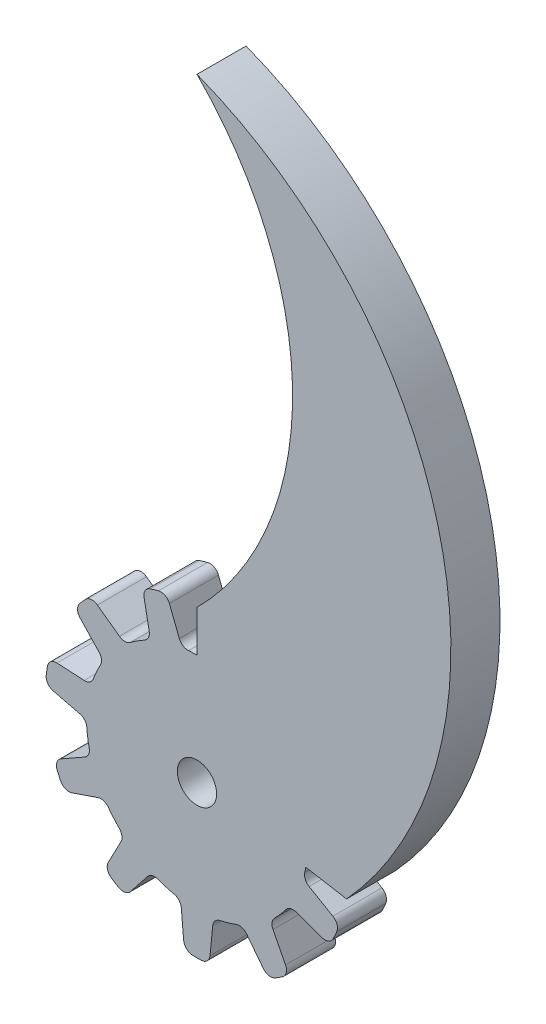
from build123d import *

# Parameters (mm, degrees)
ESBO_O1_R                = 1.6
RESSALTO_EXTRUS_O1_DEPTH = 4
RESSALTO_EXTRUS_O2_START = -4
RESSALTO_EXTRUS_O2_DEPTH = 4


with BuildPart() as part:
    # Esboço1 → Ressalto-extrusão1 (new body)
    with BuildSketch(Plane.XY):
        with BuildLine():
            Line((-5.428931338, -10.411256864), (-4.040153116, -8.653603149))
            ThreePointArc((-4.040153116, -8.653603149), (-3.651813796, -8.395770502), (-3.186165661, -8.417146095))
            ThreePointArc((-3.186165661, -8.417146095), (-2.535977815, -8.635323765), (-1.871064211, -8.803358377))
            ThreePointArc((-1.871064211, -8.803358377), (-1.465141223, -9.040151498), (-1.27980553, -9.472002324))
            Line((-1.27980553, -9.472002324), (-1.087391415, -11.684866251))
            ThreePointArc((-1.087391415, -11.684866251), (-0.855086446, -12.165243662), (-0.362160028, -12.369575749))
            ThreePointArc((-0.362160028, -12.369575749), (-0.013315066, -12.374869163), (0.335540479, -12.370326458))
            ThreePointArc((0.335540479, -12.370326458), (0.826548297, -12.16926195), (1.061642754, -11.693608494))
            Line((1.061642754, -11.693608494), (1.279697998, -9.464145904))
            ThreePointArc((1.279697998, -9.464145904), (1.466994971, -9.037291191), (1.870279627, -8.803525096))
            ThreePointArc((1.870279627, -8.803525096), (2.535208203, -8.635549743), (3.185415492, -8.41743002))
            ThreePointArc((3.185415492, -8.41743002), (3.654919666, -8.397174533), (4.044310156, -8.660270526))
            Line((4.044310156, -8.660270526), (5.402543773, -10.417823198))
            ThreePointArc((5.402543773, -10.417823198), (5.857682784, -10.696348844), (6.382829142, -10.601747792))
            ThreePointArc((6.382829142, -10.601747792), (6.679158034, -10.41760107), (6.970178022, -10.225173956))
            ThreePointArc((6.970178022, -10.225173956), (7.274536404, -9.790568861), (7.215152773, -9.263322051))
            Line((7.215152773, -9.263322051), (6.19325404, -7.269889205))
            ThreePointArc((6.19325404, -7.269889205), (6.120043199, -6.809535782), (6.332924348, -6.394847082))
            ThreePointArc((6.332924348, -6.394847082), (6.80148353, -5.894049694), (7.230548283, -5.359027107))
            ThreePointArc((7.230548283, -5.359027107), (7.614569385, -5.088153986), (8.084385943, -5.098964027))
            Line((8.084385943, -5.098964027), (10.177209485, -5.843194888))
            ThreePointArc((10.177209485, -5.843194888), (10.710679119, -5.831438844), (11.101315158, -5.46793982))
            ThreePointArc((11.101315158, -5.46793982), (11.251045651, -5.152818244), (11.391833292, -4.833600971))
            ThreePointArc((11.391833292, -4.833600971), (11.412910602, -4.303439334), (11.077902766, -3.891996308))
            Line((11.077902766, -3.891996308), (9.140495683, -2.76749405))
            ThreePointArc((9.140495683, -2.76749405), (8.830020954, -2.419800875), (8.784910335, -1.955850303))
            ThreePointArc((8.784910335, -1.955850303), (8.908335893, -1.281230512), (8.980033083, -0.599170952))
            ThreePointArc((8.980033083, -0.599170952), (9.156647127, -0.163680499), (9.557726315, 0.081227523))
            Line((9.557726315, 0.081227523), (11.720683094, 0.586606513))
            ThreePointArc((11.720683094, 0.586606513), (12.163110512, 0.884911785), (12.295212049, 1.401900411))
            ThreePointArc((12.295212049, 1.401900411), (12.25080577, 1.747947966), (12.196661982, 2.09260617))
            ThreePointArc((12.196661982, 2.09260617), (11.927766323, 2.550001774), (11.423496904, 2.715010763))
            Line((11.423496904, 2.715010763), (9.185694531, 2.613560912))
            ThreePointArc((9.185694531, 2.613560912), (8.736529446, 2.738203711), (8.447749362, 3.104115127))
            ThreePointArc((8.447749362, 3.104115127), (8.186854553, 3.738370305), (7.878420829, 4.350917747))
            ThreePointArc((7.878420829, 4.350917747), (7.791554103, 4.812760389), (7.996556113, 5.235629909))
            Line((7.996556113, 5.235629909), (9.542922635, 6.83016449))
            ThreePointArc((9.542922635, 6.83016449), (9.753840257, 7.320309176), (9.585465989, 7.826647167))
            ThreePointArc((9.585465989, 7.826647167), (9.361021617, 8.093753047), (9.129136671, 8.354425638))
            ThreePointArc((9.129136671, 8.354425638), (8.655640515, 8.593835336), (8.142211489, 8.4600211))
            Line((8.142211489, 8.4600211), (6.314500268, 7.16482875))
            ThreePointArc((6.314500268, 7.16482875), (5.869251568, 7.026847967), (5.428487655, 7.178545938))
            ThreePointArc((5.428487655, 7.178545938), (4.866104738, 7.571064963), (4.275465628, 7.919620803))
            ThreePointArc((4.275465628, 7.919620803), (3.952697704, 8.26118386), (3.896535847, 8.727756791))
            Line((3.896535847, 8.727756791), (4.335351667, 10.905193502))
            ThreePointArc((4.335351667, 10.905193502), (4.247794638, 11.431560125), (3.832402205, 11.766488747))
            ThreePointArc((3.832402205, 11.766488747), (3.499179242, 11.869848724), (3.16317497, 11.963773995))
            ThreePointArc((3.16317497, 11.963773995), (2.635410001, 11.909186901), (2.275831457, 11.519034514))
            Line((2.275831457, 11.519034514), (1.438496786, 9.441314085))
            ThreePointArc((1.438496786, 9.441314085), (1.138527788, 9.084517642), (0.685719474, 8.973839134))
            ThreePointArc((0.685719474, 8.973839134), (0.000401051, 8.999999991), (-0.684919701, 8.973900211))
            ThreePointArc((-0.684919701, 8.973900211), (-1.141112287, 9.086739826), (-1.440607019, 9.44888256))
            Line((-1.440607019, 9.44888256), (-2.248662823, 11.517900629))
            ThreePointArc((-2.248662823, 11.517900629), (-2.606895765, 11.913371507), (-3.137422201, 11.970553289))
            ThreePointArc((-3.137422201, 11.970553289), (-3.473627818, 11.877351299), (-3.807072434, 11.774708641))
            ThreePointArc((-3.807072434, 11.774708641), (-4.221544568, 11.44345577), (-4.313108983, 10.920835859))
            Line((-4.313108983, 10.920835859), (-3.894219261, 8.720248907))
            ThreePointArc((-3.894219261, 8.720248907), (-3.953670521, 8.257917155), (-4.274759795, 7.920001811))
            ThreePointArc((-4.274759795, 7.920001811), (-4.865429967, 7.571498612), (-5.427847864, 7.179029709))
            ThreePointArc((-5.427847864, 7.179029709), (-5.87262719, 7.0273201), (-6.320367336, 7.170054878))
            Line((-6.320367336, 7.170054878), (-8.118742756, 8.473755688))
            ThreePointArc((-8.118742756, 8.473755688), (-8.633915182, 8.612771611), (-9.111137226, 8.374051741))
            ThreePointArc((-9.111137226, 8.374051741), (-9.343582589, 8.113878758), (-9.56860124, 7.847256489))
            ThreePointArc((-9.56860124, 7.847256489), (-9.738188564, 7.344508289), (-9.532667795, 6.855348982))
            Line((-9.532667795, 6.855348982), (-7.990548209, 5.230566315))
            ThreePointArc((-7.990548209, 5.230566315), (-7.790606374, 4.809486318), (-7.878033033, 4.351619874))
            ThreePointArc((-7.878033033, 4.351619874), (-8.186521347, 3.739099922), (-8.447472682, 3.104867999))
            ThreePointArc((-8.447472682, 3.104867999), (-8.739624454, 2.736775896), (-9.19345568, 2.614785434))
            Line((-9.19345568, 2.614785434), (-11.411179228, 2.739253189))
            ThreePointArc((-11.411179228, 2.739253189), (-11.919727533, 2.577677583), (-12.192130558, 2.118847933))
            ThreePointArc((-12.192130558, 2.118847933), (-12.247015907, 1.774307042), (-12.292166761, 1.428355848))
            ThreePointArc((-12.292166761, 1.428355848), (-12.163026498, 0.913731319), (-11.725671937, 0.61333724))
            Line((-11.725671937, 0.61333724), (-9.549934558, 0.080215876))
            ThreePointArc((-9.549934558, 0.080215876), (-9.15407975, -0.165922443), (-8.980086447, -0.598370627))
            ThreePointArc((-8.980086447, -0.598370627), (-8.908450044, -1.280436574), (-8.78508461, -1.955067363))
            ThreePointArc((-8.78508461, -1.955067363), (-8.831852706, -2.422675318), (-9.147686805, -2.77065991))
            Line((-9.147686805, -2.77065991), (-11.080646922, -3.864942843))
            ThreePointArc((-11.080646922, -3.864942843), (-11.421110614, -4.275810864), (-11.402208583, -4.809075122))
            ThreePointArc((-11.402208583, -4.809075122), (-11.262108208, -5.128594624), (-11.113056187, -5.444037682))
            ThreePointArc((-11.113056187, -5.444037682), (-10.726189458, -5.807148888), (-10.195858089, -5.823404741))
            Line((-10.195858089, -5.823404741), (-8.077284162, -5.095602537))
            ThreePointArc((-8.077284162, -5.095602537), (-7.611197484, -5.088652), (-7.231025864, -5.358382681))
            ThreePointArc((-7.231025864, -5.358382681), (-6.802008795, -5.893443506), (-6.333494247, -6.394282651))
            ThreePointArc((-6.333494247, -6.394282651), (-6.120030126, -6.812944237), (-6.197592003, -7.27644031))
            Line((-6.197592003, -7.27644031), (-7.232087511, -9.242046831))
            ThreePointArc((-7.232087511, -9.242046831), (-7.296371772, -9.771759573), (-6.992165948, -10.210150805))
            ThreePointArc((-6.992165948, -10.210150805), (-6.701560727, -10.403203734), (-6.405628795, -10.587987714))
            ThreePointArc((-6.405628795, -10.587987714), (-5.883863054, -10.684300355), (-5.428931338, -10.411256864))
        make_face()
        Circle(ESBO_O1_R, mode=Mode.SUBTRACT)
    extrude(amount=RESSALTO_EXTRUS_O1_DEPTH)

    # Esboço6 → Ressalto-extrusão2 (add)
    with BuildSketch(Plane.XY.offset(4).offset(RESSALTO_EXTRUS_O2_START)):
        with BuildLine():
            Line((0, 12.37), (0, 9))
            ThreePointArc((0, 9), (6.887269468, 5.79357569), (8.867092658, -1.540995716))
            Line((8.867092658, -1.540995716), (12.192130558, -2.118847933))
            ThreePointArc((12.192130558, -2.118847933), (19.845997755, 27.157089417), (0, 50))
            ThreePointArc((0, 50), (7.793428176, 31.185), (0, 12.37))
        make_face()
    extrude(amount=RESSALTO_EXTRUS_O2_DEPTH)


solid = part.part
